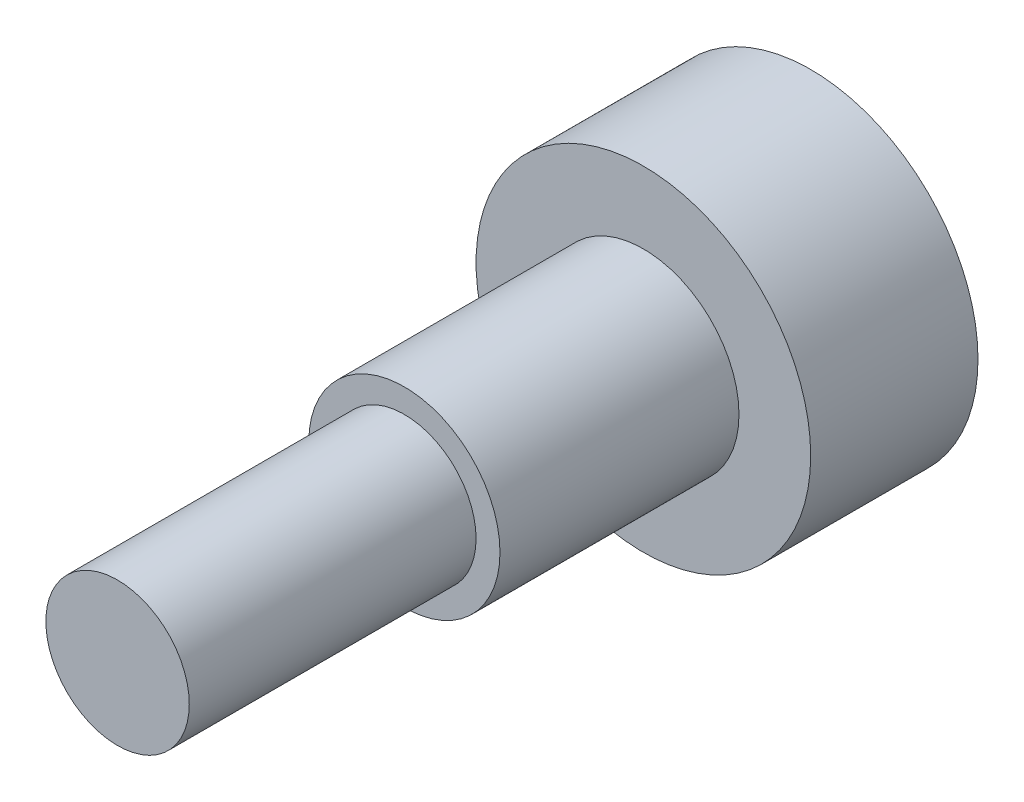
from build123d import *

# Parameters (mm, degrees)
SKETCH_1_R      = 3.5
EXTRUDE_1_DEPTH = 3.5
SKETCH_2_R      = 2
EXTRUDE_2_DEPTH = 5
SKETCH_3_R      = 1.5
EXTRUDE_3_DEPTH = 6


with BuildPart() as part:
    # 草图1 → 凸台-拉伸1 (new body)
    with BuildSketch(Plane.XY):
        Circle(SKETCH_1_R)
    extrude(amount=EXTRUDE_1_DEPTH)

    # 草图2 → 凸台-拉伸2 (add)
    with BuildSketch(Plane.XY.offset(3.5)):
        Circle(SKETCH_2_R)
    extrude(amount=EXTRUDE_2_DEPTH)

    # 草图3 → 凸台-拉伸3 (add)
    with BuildSketch(Plane.XY.offset(8.5)):
        Circle(SKETCH_3_R)
    extrude(amount=EXTRUDE_3_DEPTH)


solid = part.part
